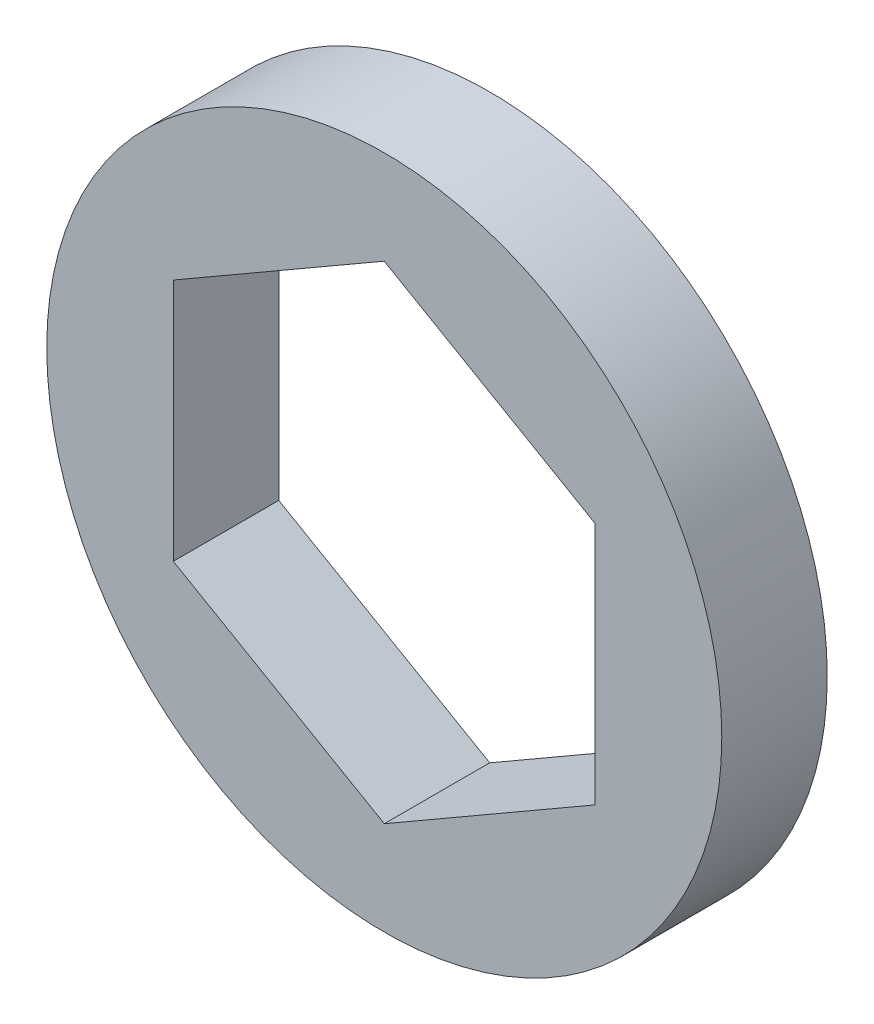
from build123d import *

# Parameters (mm, degrees)
SKETCH1_R           = 10.16
BOSS_EXTRUDE1_DEPTH = 3.175


with BuildPart() as part:
    # Sketch1 → Boss-Extrude1 (new body)
    with BuildSketch(Plane.XY):
        Circle(SKETCH1_R)
        Polygon((0, 7.332348419), (-6.35, 3.666174209), (-6.35, -3.666174209), (0, -7.332348419), (6.35, -3.666174209), (6.35, 3.666174209), align=None, mode=Mode.SUBTRACT)
    extrude(amount=BOSS_EXTRUDE1_DEPTH)


solid = part.part
